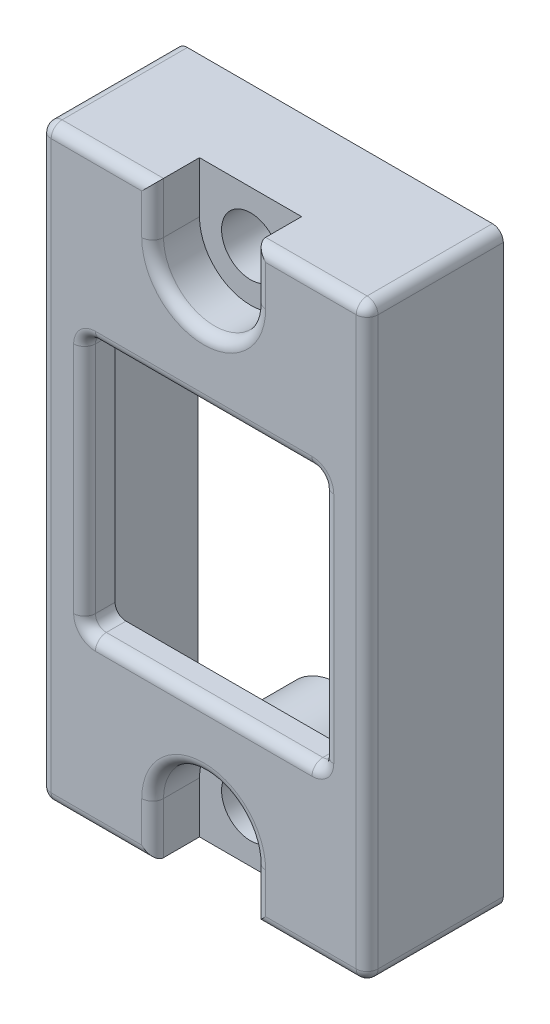
from build123d import *

# Parameters (mm, degrees)
BOSS_EXTRUDE1_DEPTH                            = 6.35
SKETCH2_W                                      = 11.1125
SKETCH2_H                                      = 11.90625
CUT_EXTRUDE1_DEPTH                             = 7.35
SHELL1_T                                       = -1
BOSS_EXTRUDE2_REACH                            = 8.35
SKETCH5_W                                      = 5.7752
SKETCH5_H                                      = 5.7752
CBORE_FOR_2_SOCKET_HEAD_CAP_SCREW2_D           = 2.7051
CBORE_FOR_2_SOCKET_HEAD_CAP_SCREW2_CBORE_D     = 4.7625
CBORE_FOR_2_SOCKET_HEAD_CAP_SCREW2_CBORE_DEPTH = 2.1844
CUT_EXTRUDE2_DEPTH                             = 4.9276
SKETCH7_W                                      = 11.1125
SKETCH7_H                                      = 11.90625
BOSS_EXTRUDE4_DEPTH                            = 0.4224
SKETCH8_W                                      = 4.7625
SKETCH8_H                                      = 2.3876
CUT_EXTRUDE3_DEPTH                             = 2.1844
FILLET1_R                                      = 0.508


with BuildPart() as part:
    # Sketch1 → Boss-Extrude1 (new body)
    with BuildSketch(Plane.XY):
        Polygon((81.28, -96.5042297), (81.28, -72.1202297), (81.28, -70.5962297), (66.04, -70.5962297), (66.04, -72.1202297), (66.04, -96.5042297), (66.04, -98.0282297), (81.28, -98.0282297), align=None)
    extrude(amount=BOSS_EXTRUDE1_DEPTH)

    # Sketch2 → Cut-Extrude1 (cut, through all)
    with BuildSketch(Plane.XY.offset(6.35)):
        with Locations((73.66, -84.3122297)):
            Rectangle(SKETCH2_W, SKETCH2_H)
    extrude(amount=-CUT_EXTRUDE1_DEPTH, mode=Mode.SUBTRACT)

    # Shell1
    shell1_openings = [part.faces().sort_by_distance(p)[0] for p in [
        (73.66, -90.2653547, 3.175),
        (68.10375, -84.3122297, 3.175),
        (73.66, -78.3591047, 3.175),
        (79.21625, -84.3122297, 3.175),
        (73.66, -84.3122297, 0),
    ]]
    offset(amount=SHELL1_T, openings=shell1_openings, kind=Kind.INTERSECTION)

    # Sketch5 → Boss-Extrude2 (add, up to next)
    with BuildSketch(Plane(origin=(0, 0, 0), x_dir=(-1, 0, 0), z_dir=(0, 0, -1)), mode=Mode.PRIVATE) as boss_extrude2_sk1:
        with Locations((-73.66, -73.4838297)):
            Rectangle(SKETCH5_W, SKETCH5_H)
    boss_extrude2_tool1 = extrude(boss_extrude2_sk1.sketch, amount=-BOSS_EXTRUDE2_REACH, mode=Mode.PRIVATE) - part.part
    add(boss_extrude2_tool1.solids().sort_by_distance((73.66, -73.48383, 0))[0])
    # Sketch5 → Boss-Extrude2 (add, up to next)
    with BuildSketch(Plane(origin=(0, 0, 0), x_dir=(-1, 0, 0), z_dir=(0, 0, -1)), mode=Mode.PRIVATE) as boss_extrude2_sk2:
        with Locations((-73.66, -95.1406297)):
            Rectangle(SKETCH5_W, SKETCH5_H)
    boss_extrude2_tool2 = extrude(boss_extrude2_sk2.sketch, amount=-BOSS_EXTRUDE2_REACH, mode=Mode.PRIVATE) - part.part
    add(boss_extrude2_tool2.solids().sort_by_distance((73.66, -95.14063, 0))[0])

    # CBORE for #2 Socket Head Cap Screw2 (through all)
    with Locations(Plane.XY.offset(6.35)):
        with Locations((73.66, -95.6406297), (73.66, -72.9838297)):
            CounterBoreHole(CBORE_FOR_2_SOCKET_HEAD_CAP_SCREW2_D / 2, CBORE_FOR_2_SOCKET_HEAD_CAP_SCREW2_CBORE_D / 2, CBORE_FOR_2_SOCKET_HEAD_CAP_SCREW2_CBORE_DEPTH)

    # Sketch6 → Cut-Extrude2 (cut)
    with BuildSketch(Plane(origin=(0, 0, 0), x_dir=(-1, 0, 0), z_dir=(0, 0, -1))):
        with BuildLine():
            Line((-76.5476, -95.6406297), (-76.8016, -95.6406297))
            Line((-76.8016, -95.6406297), (-76.8016, -92.2530297))
            Line((-76.8016, -92.2530297), (-70.5184, -92.2530297))
            Line((-70.5184, -92.2530297), (-70.5184, -95.6406297))
            Line((-70.5184, -95.6406297), (-70.7724, -95.6406297))
            ThreePointArc((-70.7724, -95.6406297), (-73.66, -92.7530297), (-76.5476, -95.6406297))
        make_face()
        with BuildLine():
            Line((-76.8016, -72.9838297), (-76.8016, -76.3714297))
            Line((-76.8016, -76.3714297), (-70.5184, -76.3714297))
            Line((-70.5184, -76.3714297), (-70.5184, -72.9838297))
            Line((-70.5184, -72.9838297), (-70.7724, -72.9838297))
            ThreePointArc((-70.7724, -72.9838297), (-73.66, -75.8714297), (-76.5476, -72.9838297))
            Line((-76.5476, -72.9838297), (-76.8016, -72.9838297))
        make_face()
    extrude(amount=-CUT_EXTRUDE2_DEPTH, mode=Mode.SUBTRACT)

    # Sketch7 → Boss-Extrude4 (add)
    with BuildSketch(Plane(origin=(0, 0, 5.35), x_dir=(-1, 0, 0), z_dir=(0, 0, -1))):
        Polygon((-70.7724, -76.3714297), (-76.5476, -76.3714297), (-76.5476, -71.5962297), (-80.28, -71.5962297), (-80.28, -97.0282297), (-76.5476, -97.0282297), (-76.5476, -92.2530297), (-70.7724, -92.2530297), (-70.7724, -97.0282297), (-67.04, -97.0282297), (-67.04, -71.5962297), (-70.7724, -71.5962297), align=None)
        with Locations((-73.66, -84.3122297)):
            Rectangle(SKETCH7_W, SKETCH7_H, mode=Mode.SUBTRACT)
    extrude(amount=BOSS_EXTRUDE4_DEPTH)

    # Sketch8 → Cut-Extrude3 (cut)
    with BuildSketch(Plane.XY.offset(6.35)):
        with Locations((73.66, -96.8344297)):
            Rectangle(SKETCH8_W, SKETCH8_H)
        with Locations((73.66, -71.7900297)):
            Rectangle(SKETCH8_W, SKETCH8_H)
    extrude(amount=-CUT_EXTRUDE3_DEPTH, mode=Mode.SUBTRACT)

    # Fillet1
    fillet1_edges = [part.edges().sort_by_distance(p)[0] for p in [
        (73.66, -93.2593797, 6.35),
        (78.660625, -70.5962297, 6.35),
        (81.28, -98.0282297, 3.175),
        (66.04, -98.0282297, 3.175),
        (66.04, -70.5962297, 3.175),
        (81.28, -70.5962297, 3.175),
        (66.04, -84.3122297, 6.35),
        (78.660625, -98.0282297, 6.35),
        (76.04125, -96.8344297, 6.35),
        (71.27875, -96.8344297, 6.35),
        (73.66, -75.3650797, 6.35),
        (68.659375, -70.5962297, 6.35),
        (71.27875, -71.7900297, 6.35),
        (76.04125, -71.7900297, 6.35),
        (68.659375, -98.0282297, 6.35),
        (79.21625, -90.2653547, 5.6388),
        (68.10375, -90.2653547, 5.6388),
        (68.10375, -78.3591047, 5.6388),
        (79.21625, -78.3591047, 5.6388),
        (73.66, -90.2653547, 6.35),
        (79.21625, -84.3122297, 6.35),
        (73.66, -78.3591047, 6.35),
        (68.10375, -84.3122297, 6.35),
        (81.28, -84.3122297, 6.35),
    ]]
    fillet(fillet1_edges, radius=FILLET1_R)


solid = part.part
